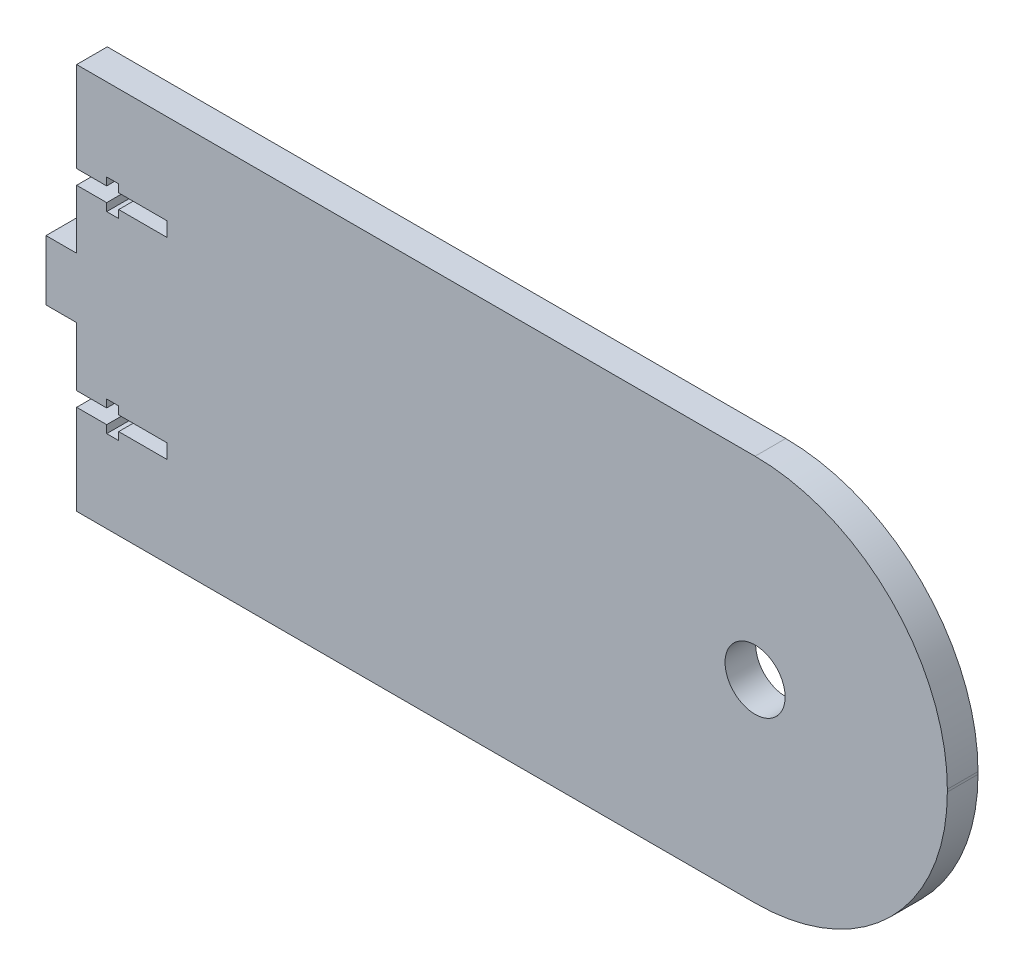
from build123d import *

# Parameters (mm, degrees)
SKETCH1_R           = 6.35
BOSS_EXTRUDE1_DEPTH = 6.477


with BuildPart() as part:
    # Sketch1 → Boss-Extrude1 (new body)
    with BuildSketch(Plane.XY):
        with BuildLine():
            Line((-88.773, 18.796), (-88.773, 6.35))
            Line((-88.773, 6.35), (-95.25, 6.35))
            Line((-95.25, 6.35), (-95.25, -6.35))
            Line((-95.25, -6.35), (-88.773, -6.35))
            Line((-88.773, -6.35), (-88.773, -18.796))
            Line((-88.773, -18.796), (-82.423, -18.796))
            Line((-82.423, -18.796), (-82.423, -17.145))
            Line((-82.423, -17.145), (-79.883, -17.145))
            Line((-79.883, -17.145), (-79.883, -18.796))
            Line((-79.883, -18.796), (-69.723, -18.796))
            Line((-69.723, -18.796), (-69.723, -21.844))
            Line((-69.723, -21.844), (-79.883, -21.844))
            Line((-79.883, -21.844), (-79.883, -23.495))
            Line((-79.883, -23.495), (-82.423, -23.495))
            Line((-82.423, -23.495), (-82.423, -21.844))
            Line((-82.423, -21.844), (-88.773, -21.844))
            Line((-88.773, -21.844), (-88.773, -40.894))
            Line((-88.773, -40.894), (54.61, -40.894))
            ThreePointArc((54.61, -40.894), (83.346819587, -28.990819587), (95.25, -0.254))
            Line((95.25, -0.254), (95.25, 0.254))
            ThreePointArc((95.25, 0.254), (83.346819587, 28.990819587), (54.61, 40.894))
            Line((54.61, 40.894), (-88.773, 40.894))
            Line((-88.773, 40.894), (-88.773, 21.844))
            Line((-88.773, 21.844), (-82.423, 21.844))
            Line((-82.423, 21.844), (-82.423, 23.495))
            Line((-82.423, 23.495), (-79.883, 23.495))
            Line((-79.883, 23.495), (-79.883, 21.844))
            Line((-79.883, 21.844), (-69.723, 21.844))
            Line((-69.723, 21.844), (-69.723, 18.796))
            Line((-69.723, 18.796), (-79.883, 18.796))
            Line((-79.883, 18.796), (-79.883, 17.145))
            Line((-79.883, 17.145), (-82.423, 17.145))
            Line((-82.423, 17.145), (-82.423, 18.796))
            Line((-82.423, 18.796), (-88.773, 18.796))
        make_face()
        with Locations((54.61, 0)):
            Circle(SKETCH1_R, mode=Mode.SUBTRACT)
    extrude(amount=BOSS_EXTRUDE1_DEPTH)


solid = part.part
